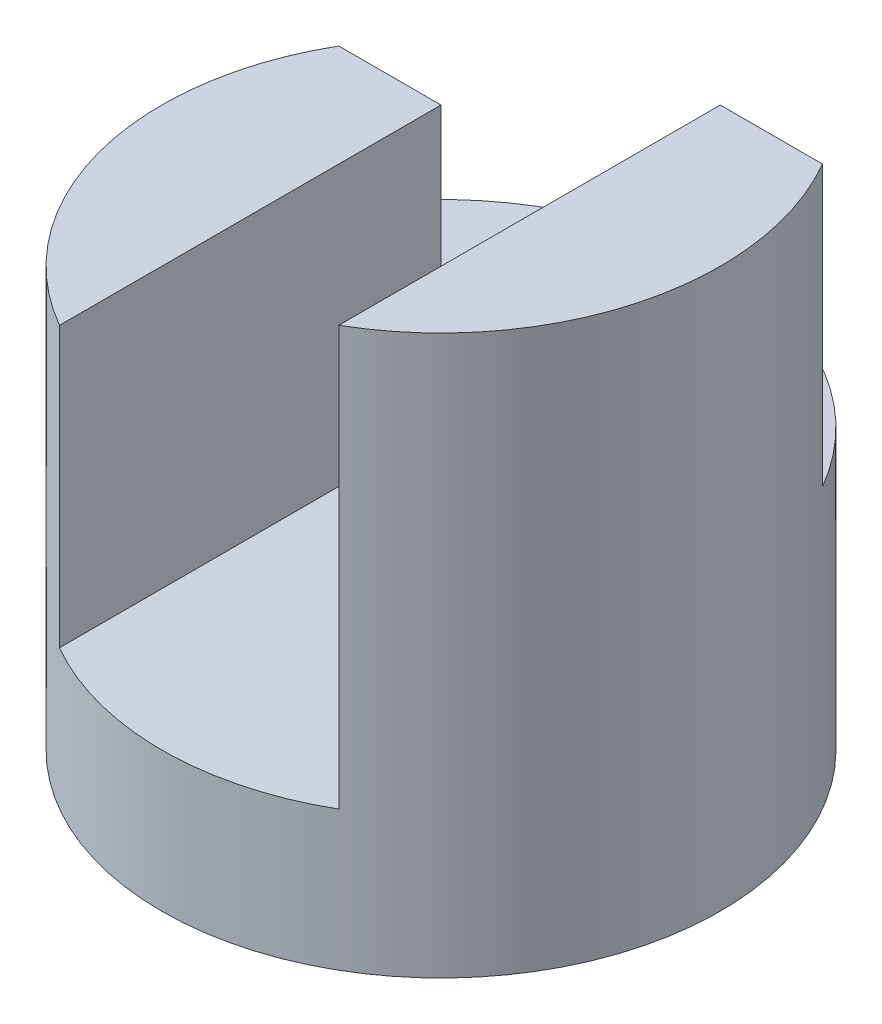
from build123d import *

# Parameters (mm, degrees)
SKETCH1_R           = 2
BOSS_EXTRUDE1_DEPTH = 4
CUT_EXTRUDE2_DEPTH  = 2
CUT_EXTRUDE3_DEPTH  = 5.5
SKETCH5_W           = 2
SKETCH5_H           = 3.090553664
CUT_EXTRUDE4_DEPTH  = 1


with BuildPart() as part:
    # Sketch1 → Boss-Extrude1 (new body)
    with BuildSketch(Plane(origin=(0, 0, 0), x_dir=(1, 0, 0), z_dir=(0, 1, 0))):
        Circle(SKETCH1_R)
    extrude(amount=BOSS_EXTRUDE1_DEPTH)

    # Sketch3 → Cut-Extrude2 (cut)
    with BuildSketch(Plane(origin=(0, 4, 0), x_dir=(1, 0, 0), z_dir=(0, 1, 0))):
        with BuildLine():
            Line((-1.732050808, 1), (1.732050808, 1))
            ThreePointArc((1.732050808, 1), (0, 2), (-1.732050808, 1))
        make_face()
    extrude(amount=-CUT_EXTRUDE2_DEPTH, mode=Mode.SUBTRACT)

    # Sketch4 → Cut-Extrude3 (cut, symmetric)
    with BuildSketch(Plane.XY):
        Polygon((-2, 3), (-1, 3), (-1, 2), (1, 2), (1, 4), (-2, 4), align=None)
    extrude(amount=CUT_EXTRUDE3_DEPTH, both=True, mode=Mode.SUBTRACT)

    # Sketch5 → Cut-Extrude4 (cut)
    with BuildSketch(Plane(origin=(0, 2, 0), x_dir=(1, 0, 0), z_dir=(0, 1, 0))):
        with Locations((0, -0.545276832)):
            Rectangle(SKETCH5_W, SKETCH5_H)
    extrude(amount=-CUT_EXTRUDE4_DEPTH, mode=Mode.SUBTRACT)


solid = part.part
